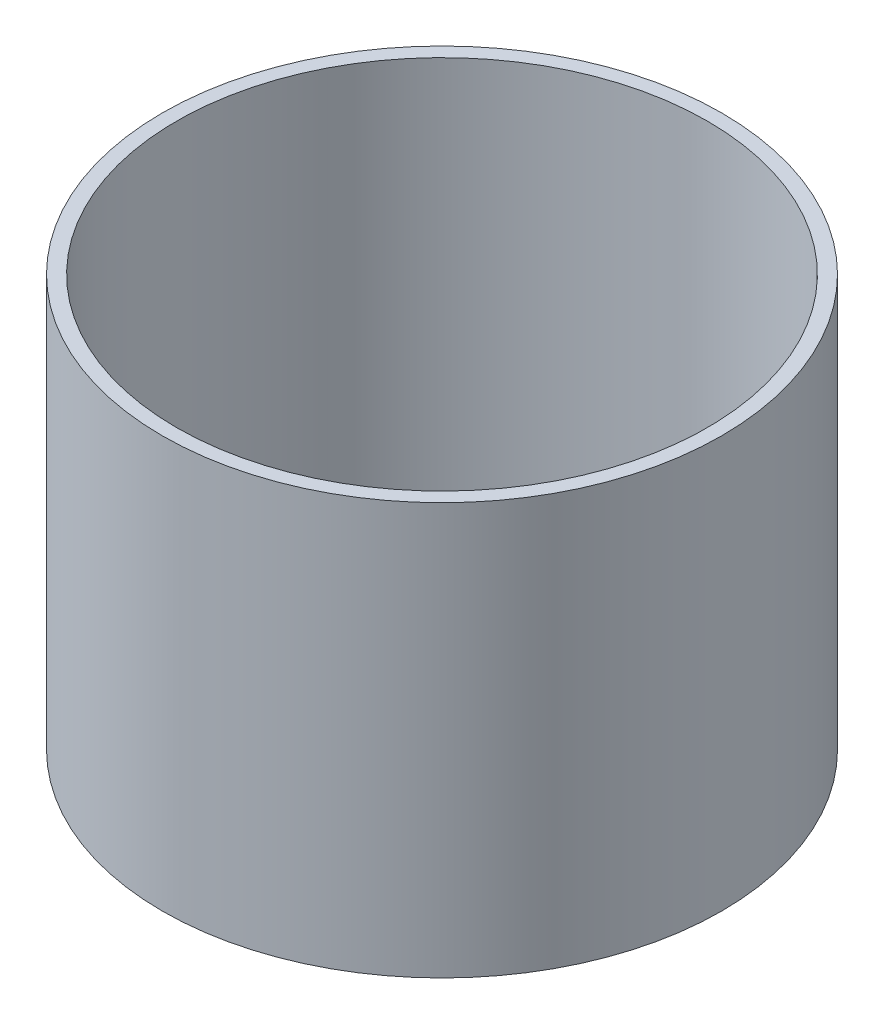
from build123d import *

# Parameters (mm, degrees)
SKETCH1_R           = 93.6625
SKETCH1_R_2         = 88.9
BOSS_EXTRUDE1_DEPTH = 68.92544


with BuildPart() as part:
    # Sketch1 → Boss-Extrude1 (new body, symmetric)
    with BuildSketch(Plane(origin=(0, 0, 0), x_dir=(1, 0, 0), z_dir=(0, 1, 0))):
        Circle(SKETCH1_R)
        Circle(SKETCH1_R_2, mode=Mode.SUBTRACT)
    extrude(amount=BOSS_EXTRUDE1_DEPTH, both=True)


solid = part.part
